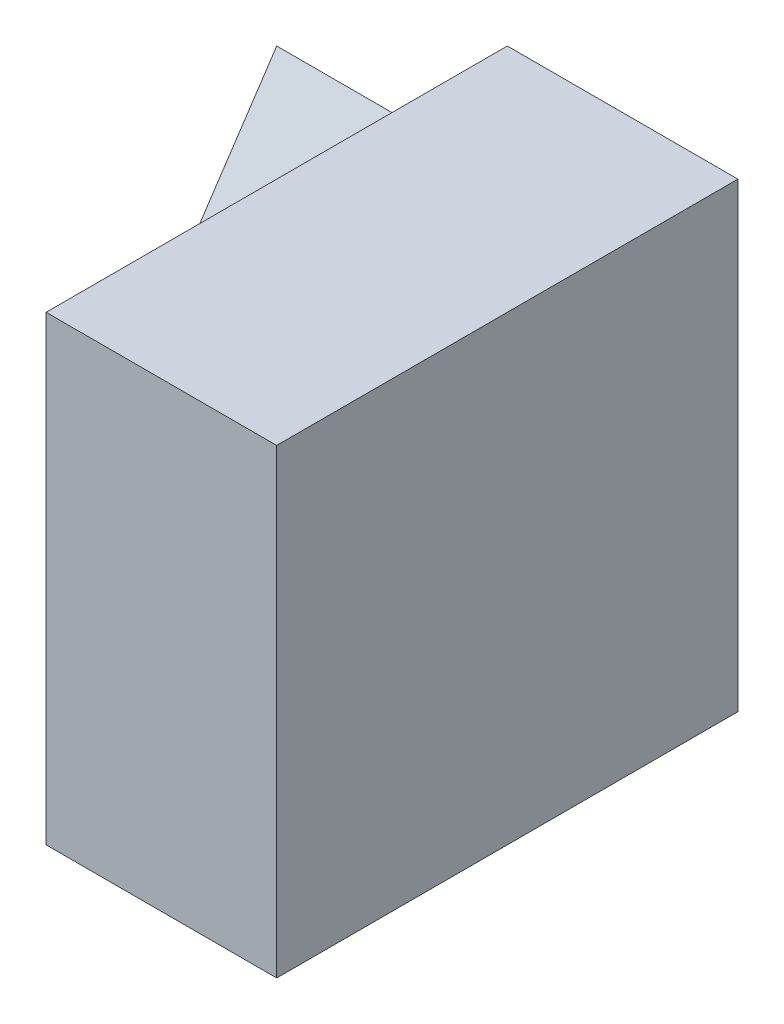
from build123d import *

# Parameters (mm, degrees)
SKETCH1_W           = 4
SKETCH1_H           = 4
BOSS_EXTRUDE1_DEPTH = 2
SKETCH2_W           = 2
SKETCH2_H           = 3
BOSS_EXTRUDE2_DEPTH = 2
CUT_EXTRUDE1_DEPTH  = 2


with BuildPart() as part:
    # Sketch1 → Boss-Extrude1 (new body)
    with BuildSketch(Plane(origin=(0, 0, 0), x_dir=(0, 0, -1), z_dir=(1, 0, 0))):
        with Locations((2, 2)):
            Rectangle(SKETCH1_W, SKETCH1_H)
    extrude(amount=BOSS_EXTRUDE1_DEPTH)

    # Sketch2 → Boss-Extrude2 (add)
    with BuildSketch(Plane.ZY):
        with Locations((-3, 1.5)):
            Rectangle(SKETCH2_W, SKETCH2_H)
    extrude(amount=BOSS_EXTRUDE2_DEPTH)

    # Sketch3 → Cut-Extrude1 (cut)
    with BuildSketch(Plane.ZY.offset(2)):
        Polygon((-4, 3), (-2, 3), (-2, 0), align=None)
    extrude(amount=-CUT_EXTRUDE1_DEPTH, mode=Mode.SUBTRACT)


solid = part.part
